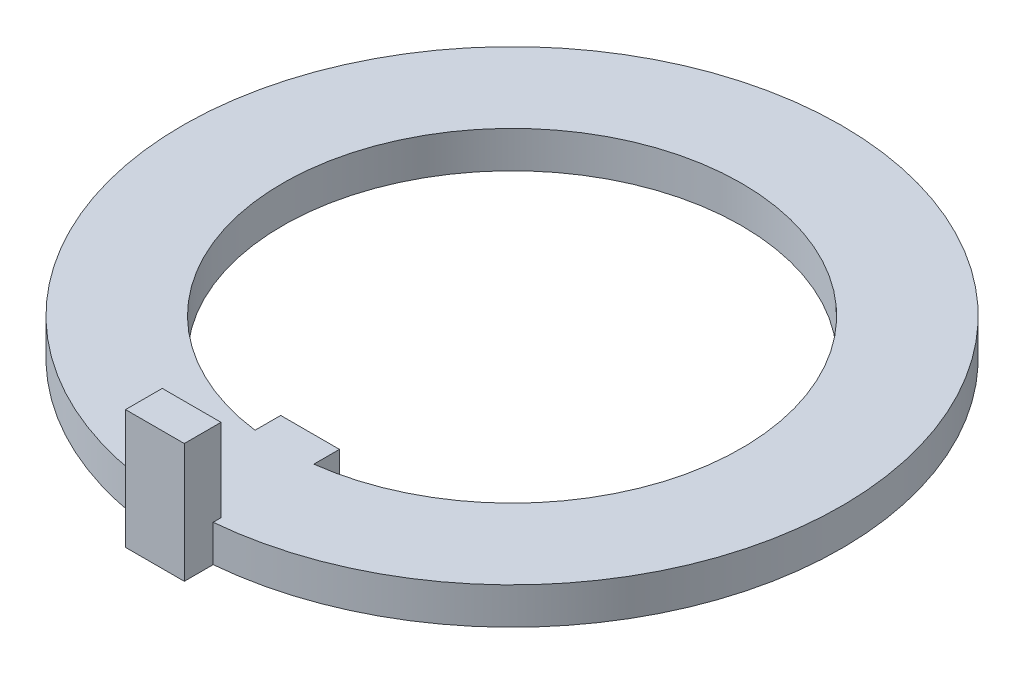
from build123d import *

# Parameters (mm, degrees)
BOSS_EXTRUDE1_DEPTH = 1.016
SKETCH2_W           = 1.6256
SKETCH2_H           = 1.016
BOSS_EXTRUDE2_DEPTH = 2.286


with BuildPart() as part:
    # Sketch1 → Boss-Extrude1 (new body)
    with BuildSketch(Plane(origin=(0, 0, 0), x_dir=(1, 0, 0), z_dir=(0, 1, 0))):
        with BuildLine():
            Line((0.8128, -9.8806), (-0.8128, -9.8806))
            Line((-0.8128, -9.8806), (-0.8128, -9.082302688))
            ThreePointArc((-0.8128, -9.082302688), (0, 9.1186), (0.8128, -9.082302688))
            Line((0.8128, -9.082302688), (0.8128, -9.8806))
        make_face()
        with BuildLine():
            Line((0.8128, -6.297765966), (0.8128, -5.588))
            Line((0.8128, -5.588), (-0.8128, -5.588))
            Line((-0.8128, -5.588), (-0.8128, -6.297765966))
            ThreePointArc((-0.8128, -6.297765966), (0, 6.35), (0.8128, -6.297765966))
        make_face(mode=Mode.SUBTRACT)
    extrude(amount=BOSS_EXTRUDE1_DEPTH)

    # Sketch2 → Boss-Extrude2 (add)
    with BuildSketch(Plane(origin=(0, 1.016, 0), x_dir=(1, 0, 0), z_dir=(0, 1, 0))):
        with Locations((0, -9.3726)):
            Rectangle(SKETCH2_W, SKETCH2_H)
    extrude(amount=BOSS_EXTRUDE2_DEPTH)


solid = part.part
